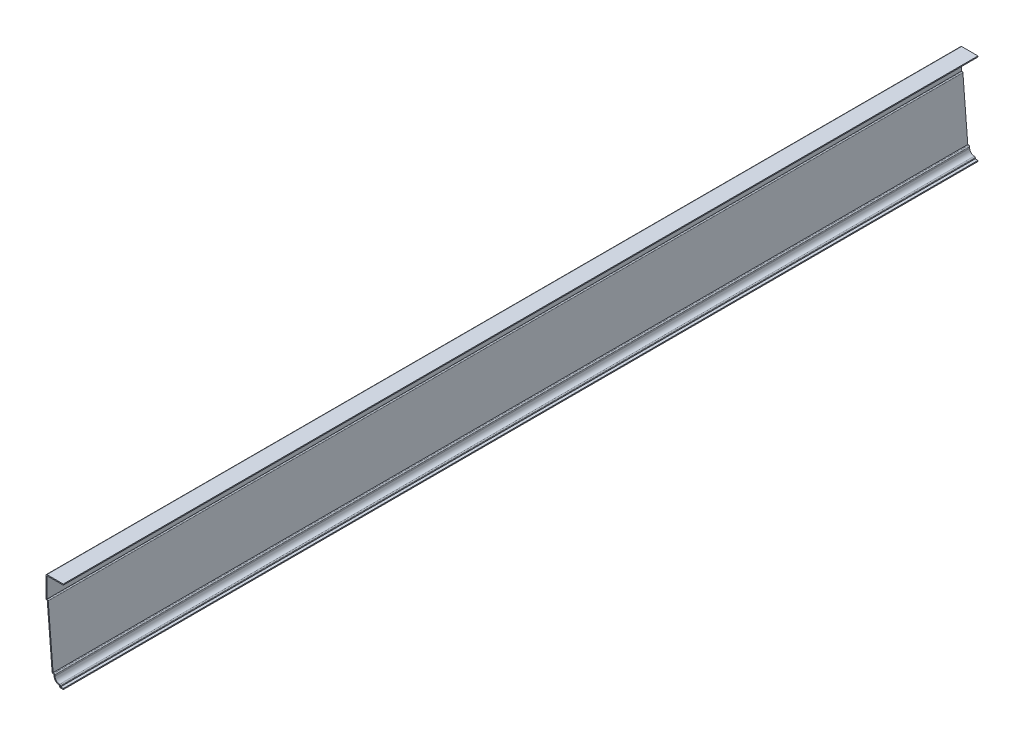
from build123d import *

# Parameters (mm, degrees)
EXTRUDE_THIN1_DEPTH = 1174.75
FILLET1_R           = 1.27


with BuildPart() as part:
    # Sketch1 → Extrude-Thin1 (new body)
    with BuildSketch(Plane.XY):
        with BuildLine():
            Line((0, 0), (-4.7625, 0))
            Line((-4.7625, 0), (-4.7625, 2.38125))
            ThreePointArc((-4.7625, 2.38125), (-9.813894, 4.473606), (-11.90625, 9.525))
            Line((-11.90625, 9.525), (-11.90625, 11.1125))
            Line((-11.90625, 11.1125), (-14.2875, 11.1125))
            Line((-14.2875, 11.1125), (-20.6375, 88.9))
            Line((-20.6375, 88.9), (-22.225, 88.9))
            Line((-22.225, 88.9), (-22.225, 117.475))
            Line((-22.225, 117.475), (0, 117.475))
            Line((0, 117.475), (0, 116.205))
            Line((0, 116.205), (-20.955, 116.205))
            Line((-20.955, 116.205), (-20.955, 90.17))
            Line((-20.955, 90.17), (-19.466949, 90.17))
            Line((-19.466949, 90.17), (-13.116949, 12.3825))
            Line((-13.116949, 12.3825), (-10.63625, 12.3825))
            Line((-10.63625, 12.3825), (-10.63625, 9.525))
            ThreePointArc((-10.63625, 9.525), (-8.439542, 4.944574), (-3.4925, 3.790191))
            Line((-3.4925, 3.790191), (-3.4925, 1.27))
            Line((-3.4925, 1.27), (0, 1.27))
            Line((0, 1.27), (0, 0))
        make_face()
    extrude(amount=-EXTRUDE_THIN1_DEPTH)

    # Fillet1
    fillet1_edges = [part.edges().sort_by_distance(p)[0] for p in [
        (-19.466949, 90.17, -587.375),
        (-10.63625, 12.3825, -587.375),
        (-3.4925, 3.790191, -587.375),
        (-4.7625, 0, -587.375),
        (-14.2875, 11.1125, -587.375),
        (-22.225, 88.9, -587.375),
        (-22.225, 117.475, -587.375),
    ]]
    fillet(fillet1_edges, radius=FILLET1_R)


solid = part.part
